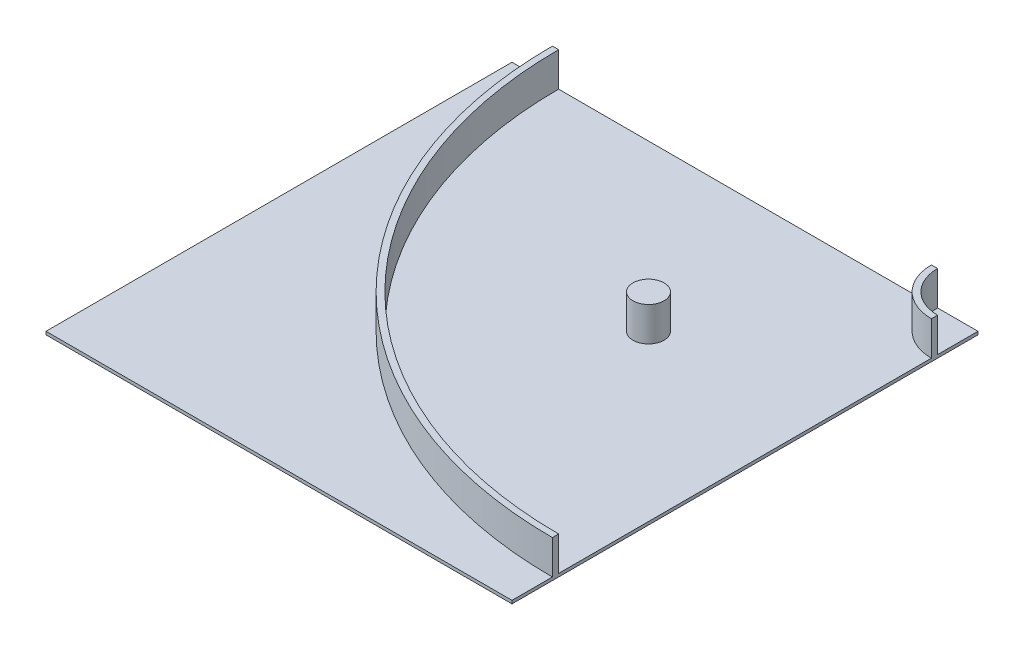
from build123d import *

# Parameters (mm, degrees)
SKETCH2_W           = 1500
SKETCH2_H           = 1500
BOSS_EXTRUDE1_DEPTH = 10
BOSS_EXTRUDE2_DEPTH = 110
BOSS_EXTRUDE3_DEPTH = 110


with BuildPart() as part:
    # Sketch2 → Boss-Extrude1 (new body)
    with BuildSketch(Plane(origin=(0, 0, 0), x_dir=(1, 0, 0), z_dir=(0, 1, 0))):
        Rectangle(SKETCH2_W, SKETCH2_H)
    extrude(amount=BOSS_EXTRUDE1_DEPTH)

    # Sketch3 → Boss-Extrude2 (add)
    with BuildSketch(Plane(origin=(0, 10, 0), x_dir=(1, 0, 0), z_dir=(0, 1, 0))):
        with BuildLine():
            ThreePointArc((750, -600), (-204.594154602, -204.594154602), (-600, 750))
            Line((-600, 750), (-620, 750))
            ThreePointArc((-620, 750), (-218.736290226, -218.736290226), (750, -620))
            Line((750, -620), (750, -600))
        make_face()
        with BuildLine():
            Line((620, 750), (600, 750))
            ThreePointArc((600, 750), (643.933982822, 643.933982822), (750, 600))
            Line((750, 600), (750, 620))
            ThreePointArc((750, 620), (658.076118446, 658.076118446), (620, 750))
        make_face()
    extrude(amount=BOSS_EXTRUDE2_DEPTH)

    # Sketch4 → Boss-Extrude3 (add)
    with BuildSketch(Plane(origin=(0, 10, 0), x_dir=(1, 0, 0), z_dir=(0, 1, 0))):
        with BuildLine():
            ThreePointArc((269.66991411, 219.66991411), (265.863890736, 238.804085728), (255.025253169, 255.025253169))
            Line((255.025253169, 255.025253169), (184.314575051, 184.314575051))
            ThreePointArc((184.314575051, 184.314575051), (238.804085728, 173.475937485), (269.66991411, 219.66991411))
        make_face()
        with BuildLine():
            Line((184.314575051, 184.314575051), (255.025253169, 255.025253169))
            ThreePointArc((255.025253169, 255.025253169), (184.314575051, 255.025253169), (184.314575051, 184.314575051))
        make_face()
    extrude(amount=BOSS_EXTRUDE3_DEPTH)


solid = part.part
